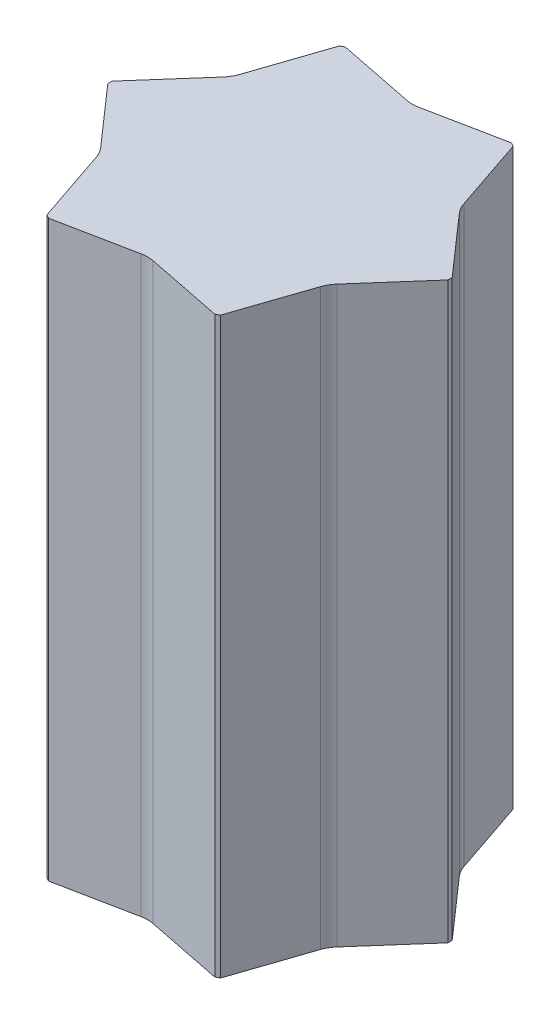
from build123d import *

# Parameters (mm, degrees)
EXTRUDE_1_DEPTH = 650


with BuildPart() as part:
    # 草图5 → 凸台-拉伸1 (new body, symmetric)
    with BuildSketch(Plane(origin=(0, 0, 0), x_dir=(1, 0, 0), z_dir=(0, 1, 0))):
        with BuildLine():
            Line((-267.514659832, 138.60716948), (-385, 4.891224703))
            Line((-385, 4.891224703), (-385, -4.891224703))
            Line((-385, -4.891224703), (-267.514659832, -138.60716948))
            ThreePointArc((-267.514659832, -138.60716948), (-259.47883349, -149.810174364), (-253.794659832, -162.37090656))
            Line((-253.794659832, -162.37090656), (-196.735924848, -330.974168106))
            Line((-196.735924848, -330.974168106), (-188.264075152, -335.865392808))
            Line((-188.264075152, -335.865392808), (-13.72, -300.978076039))
            ThreePointArc((-13.72, -300.978076039), (0, -299.620348729), (13.72, -300.978076039))
            Line((13.72, -300.978076039), (188.264075152, -335.865392808))
            Line((188.264075152, -335.865392808), (196.735924848, -330.974168106))
            Line((196.735924848, -330.974168106), (253.794659832, -162.37090656))
            ThreePointArc((253.794659832, -162.37090656), (259.47883349, -149.810174364), (267.514659832, -138.60716948))
            Line((267.514659832, -138.60716948), (385, -4.891224703))
            Line((385, -4.891224703), (385, 4.891224703))
            Line((385, 4.891224703), (267.514659832, 138.60716948))
            ThreePointArc((267.514659832, 138.60716948), (259.47883349, 149.810174364), (253.794659832, 162.37090656))
            Line((253.794659832, 162.37090656), (196.735924848, 330.974168106))
            Line((196.735924848, 330.974168106), (188.264075152, 335.865392808))
            Line((188.264075152, 335.865392808), (13.72, 300.978076039))
            ThreePointArc((13.72, 300.978076039), (0, 299.620348729), (-13.72, 300.978076039))
            Line((-13.72, 300.978076039), (-188.264075152, 335.865392808))
            Line((-188.264075152, 335.865392808), (-196.735924848, 330.974168106))
            Line((-196.735924848, 330.974168106), (-253.794659832, 162.37090656))
            ThreePointArc((-253.794659832, 162.37090656), (-259.47883349, 149.810174364), (-267.514659832, 138.60716948))
        make_face()
    extrude(amount=EXTRUDE_1_DEPTH, both=True)


solid = part.part
